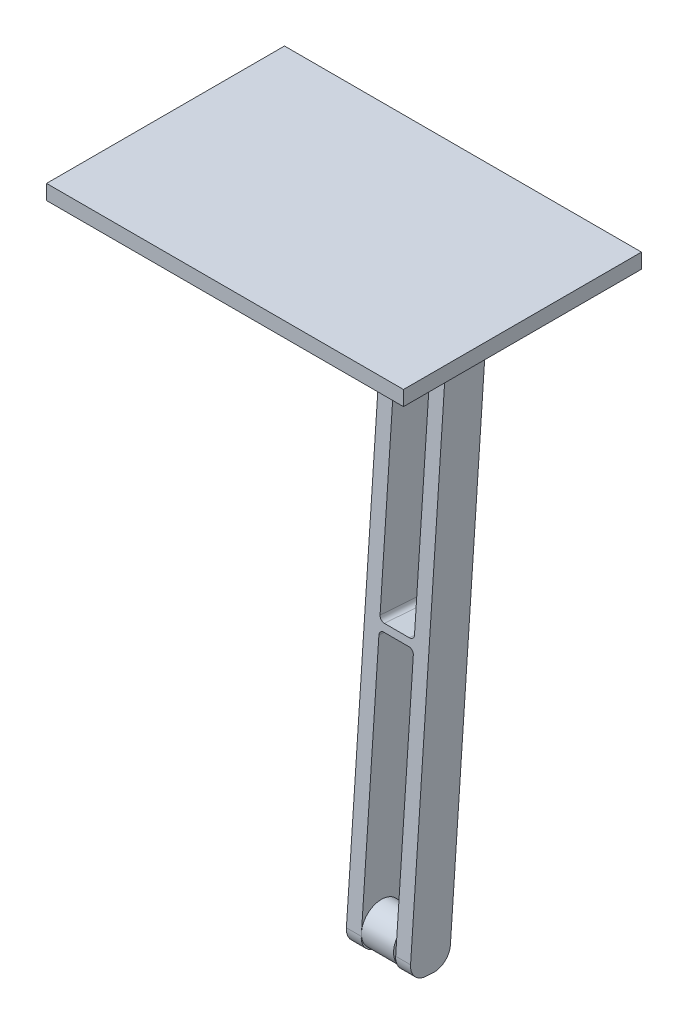
from build123d import *

# Parameters (mm, degrees)
SKETCH4_W           = 76.2
SKETCH4_H           = 3.175
BOSS_EXTRUDE4_DEPTH = 50.8
SKETCH5_W           = 7.35
SKETCH5_H           = 49.462905427
BOSS_EXTRUDE5_DEPTH = 8.525
SKETCH6_R           = 4.2625
BOSS_EXTRUDE6_DEPTH = 6.85
FILLET1_R           = 1
FILLET2_R           = 3.54


with BuildPart() as part:
    # Sketch4 → Boss-Extrude4 (new body)
    with BuildSketch(Plane.XY):
        with Locations((0, 1.5875)):
            Rectangle(SKETCH4_W, SKETCH4_H)
    extrude(amount=BOSS_EXTRUDE4_DEPTH)

    # Sketch5 → Boss-Extrude5 (add)
    with BuildSketch(Plane(origin=(0, 0, 0), x_dir=(1, 0, 0), z_dir=(0, 0.06975647374412547, 0.9975640502598243))):
        Polygon((-3.712235216, 0), (-6.887235216, 0), (-6.887235216, -139.7), (-3.712235216, -139.7), (-3.712235216, -81.218439027), (3.637764784, -81.218439027), (3.637764784, -139.7), (6.812764784, -139.7), (6.812764784, 0), (3.637764784, 0), (3.637764784, -28.5805336), (-3.712235216, -28.5805336), align=None)
        with Locations((-0.037235216, -54.899486314)):
            Rectangle(SKETCH5_W, SKETCH5_H, mode=Mode.SUBTRACT)
    extrude(amount=BOSS_EXTRUDE5_DEPTH)

    # Sketch6 → Boss-Extrude6 (add)
    with BuildSketch(Plane(origin=(-3.712235216, 0, 0), x_dir=(0, 0, -1), z_dir=(1, 0, 0))):
        with Locations((-13.699759177, -134.810244088)):
            Circle(SKETCH6_R)
    extrude(amount=BOSS_EXTRUDE6_DEPTH)

    # Fillet1
    fillet1_edges = [part.edges().sort_by_distance(p)[0] for p in [
        (6.812764784, 0, 4.272908591),
        (-6.887235216, 0, 4.272908591),
        (3.637764784, 0, 4.272908591),
        (-3.712235216, 0, 4.272908591),
        (5.225264784, 0, 8.545817181),
        (-5.299735216, 0, 8.545817181),
        (3.637764784, -79.139625092, 9.806890272),
        (3.637764784, -80.723258022, 9.917628674),
        (-3.712235216, -80.723258022, 9.917628674),
        (-3.712235216, -79.139625092, 9.806890272),
        (3.637764784, -29.797208817, 6.356532408),
        (3.637764784, -28.213575887, 6.245794006),
        (-3.712235216, -28.213575887, 6.245794006),
        (-3.712235216, -29.797208817, 6.356532408),
    ]]
    fillet(fillet1_edges, radius=FILLET1_R)

    # Fillet2
    fillet2_edges = [part.edges().sort_by_distance(p)[0] for p in [
        (5.225264784, -138.765023883, 18.249212911),
        (5.225264784, -139.359697821, 9.744979382),
        (-5.299735216, -139.359697821, 9.744979382),
        (-5.299735216, -138.765023883, 18.249212911),
    ]]
    fillet(fillet2_edges, radius=FILLET2_R)


solid = part.part
